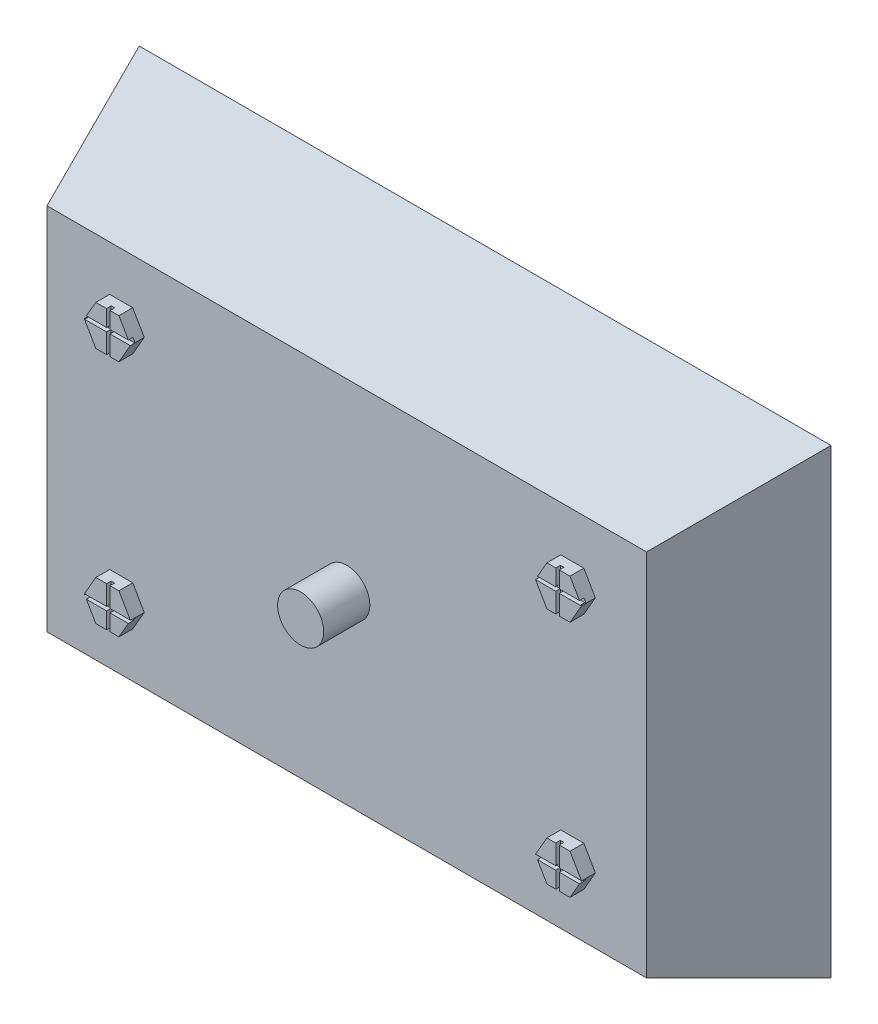
from build123d import *

# Parameters (mm, degrees)
SKETCH2_W             = 150
SKETCH2_H             = 100
BOSS_EXTRUDE1_DEPTH   = 50
CHAMFER1_SIZE         = 30
CHAMFER1_SIZE2        = 10
CHAMFER1_PART_2_SIZE  = 30
CHAMFER1_PART_2_SIZE2 = 10
CHAMFER1_PART_3_SIZE  = 30
CHAMFER1_PART_3_SIZE2 = 10
CHAMFER1_PART_4_SIZE  = 30
CHAMFER1_PART_4_SIZE2 = 10
CUT_EXTRUDE1_DEPTH    = 282
BOSS_EXTRUDE2_DEPTH   = 3
CUT_EXTRUDE2_DEPTH    = 1
SKETCH9_R             = 5
BOSS_EXTRUDE3_DEPTH   = 10


with BuildPart() as part:
    # Sketch2 → Boss-Extrude1 (new body)
    with BuildSketch(Plane.XY):
        Rectangle(SKETCH2_W, SKETCH2_H)
    extrude(amount=-BOSS_EXTRUDE1_DEPTH)

    # Chamfer1
    chamfer1_edges = [part.edges().sort_by_distance(p)[0] for p in [
        (0, -50, 0),
    ]]
    chamfer1_side = [part.faces().sort_by_distance(p)[0] for p in [
        (0, -50, -25),
    ]]
    chamfer(chamfer1_edges, length=CHAMFER1_SIZE, length2=CHAMFER1_SIZE2, reference=chamfer1_side[0])

    # Chamfer1 part 2
    chamfer1_part_2_edges = [part.edges().sort_by_distance(p)[0] for p in [
        (-75, 0, 0),
    ]]
    chamfer1_part_2_side = [part.faces().sort_by_distance(p)[0] for p in [
        (-75, 0, -25),
    ]]
    chamfer(chamfer1_part_2_edges, length=CHAMFER1_PART_2_SIZE, length2=CHAMFER1_PART_2_SIZE2, reference=chamfer1_part_2_side[0])

    # Chamfer1 part 3
    chamfer1_part_3_edges = [part.edges().sort_by_distance(p)[0] for p in [
        (0, 50, 0),
    ]]
    chamfer1_part_3_side = [part.faces().sort_by_distance(p)[0] for p in [
        (0, 50, -25),
    ]]
    chamfer(chamfer1_part_3_edges, length=CHAMFER1_PART_3_SIZE, length2=CHAMFER1_PART_3_SIZE2, reference=chamfer1_part_3_side[0])

    # Chamfer1 part 4
    chamfer1_part_4_edges = [part.edges().sort_by_distance(p)[0] for p in [
        (75, 0, 0),
    ]]
    chamfer1_part_4_side = [part.faces().sort_by_distance(p)[0] for p in [
        (75, 0, -25),
    ]]
    chamfer(chamfer1_part_4_edges, length=CHAMFER1_PART_4_SIZE, length2=CHAMFER1_PART_4_SIZE2, reference=chamfer1_part_4_side[0])

    # Sketch5 → Cut-Extrude1 (cut)
    with BuildSketch(Plane(origin=(75, 0, 0), x_dir=(0, 0, -1), z_dir=(1, 0, 0))):
        Polygon((30, -50), (30, 50), (81.32895228, 62.665959411), (65.838490403, -81.97874305), align=None)
    extrude(amount=-CUT_EXTRUDE1_DEPTH, mode=Mode.SUBTRACT)

    # Sketch6 → Boss-Extrude2 (add)
    with BuildSketch(Plane.XY):
        Polygon((-43.903010181, -25.827914317), (-46.403010181, -21.497787298), (-51.403010181, -21.497787298), (-53.903010181, -25.827914317), (-51.403010181, -30.158041336), (-46.403010181, -30.158041336), align=None)
        Polygon((43.903010181, 25.827914317), (46.403010181, 21.497787298), (51.403010181, 21.497787298), (53.903010181, 25.827914317), (51.403010181, 30.158041336), (46.403010181, 30.158041336), align=None)
        Polygon((46.403010181, -30.158041336), (43.903010181, -25.827914317), (46.403010181, -21.497787298), (51.403010181, -21.497787298), (53.903010181, -25.827914317), (51.403010181, -30.158041336), align=None)
        Polygon((-46.403010181, 21.497787298), (-51.403010181, 21.497787298), (-53.903010181, 25.827914317), (-51.403010181, 30.158041336), (-46.403010181, 30.158041336), (-43.903010181, 25.827914317), align=None)
    extrude(amount=BOSS_EXTRUDE2_DEPTH)

    # Sketch7 → Cut-Extrude2 (cut)
    with BuildSketch(Plane.XY.offset(3)):
        Polygon((-49.074995517, -20.874091647), (-48.315685666, -20.874091647), (-48.315685666, -25.776876491), (-43.576392296, -25.776876491), (-43.576392296, -26.601644718), (-48.315685666, -26.601644718), (-48.315685666, -31.504429563), (-49.074995517, -31.504429563), (-49.074995517, -26.601644718), (-53.814288887, -26.601644718), (-53.814288887, -25.776876491), (-49.074995517, -25.776876491), align=None)
        Polygon((48.315685666, -26.601644718), (48.315685666, -31.504429563), (49.074995517, -31.504429563), (49.074995517, -26.601644718), (53.814288887, -26.601644718), (53.814288887, -25.776876491), (49.074995517, -25.776876491), (49.074995517, -20.874091647), (48.315685666, -20.874091647), (48.315685666, -25.776876491), (43.576392296, -25.776876491), (43.576392296, -26.601644718), align=None)
        Polygon((-48.315685666, 26.601644718), (-48.315685666, 31.504429563), (-49.074995517, 31.504429563), (-49.074995517, 26.601644718), (-53.814288887, 26.601644718), (-53.814288887, 25.776876491), (-49.074995517, 25.776876491), (-49.074995517, 20.874091647), (-48.315685666, 20.874091647), (-48.315685666, 25.776876491), (-43.576392296, 25.776876491), (-43.576392296, 26.601644718), align=None)
        Polygon((49.074995517, 20.874091647), (48.315685666, 20.874091647), (48.315685666, 25.776876491), (43.576392296, 25.776876491), (43.576392296, 26.601644718), (48.315685666, 26.601644718), (48.315685666, 31.504429563), (49.074995517, 31.504429563), (49.074995517, 26.601644718), (53.814288887, 26.601644718), (53.814288887, 25.776876491), (49.074995517, 25.776876491), align=None)
    extrude(amount=-CUT_EXTRUDE2_DEPTH, mode=Mode.SUBTRACT)

    # Sketch9 → Boss-Extrude3 (add)
    with BuildSketch(Plane.XY):
        Circle(SKETCH9_R)
    extrude(amount=BOSS_EXTRUDE3_DEPTH)


solid = part.part
